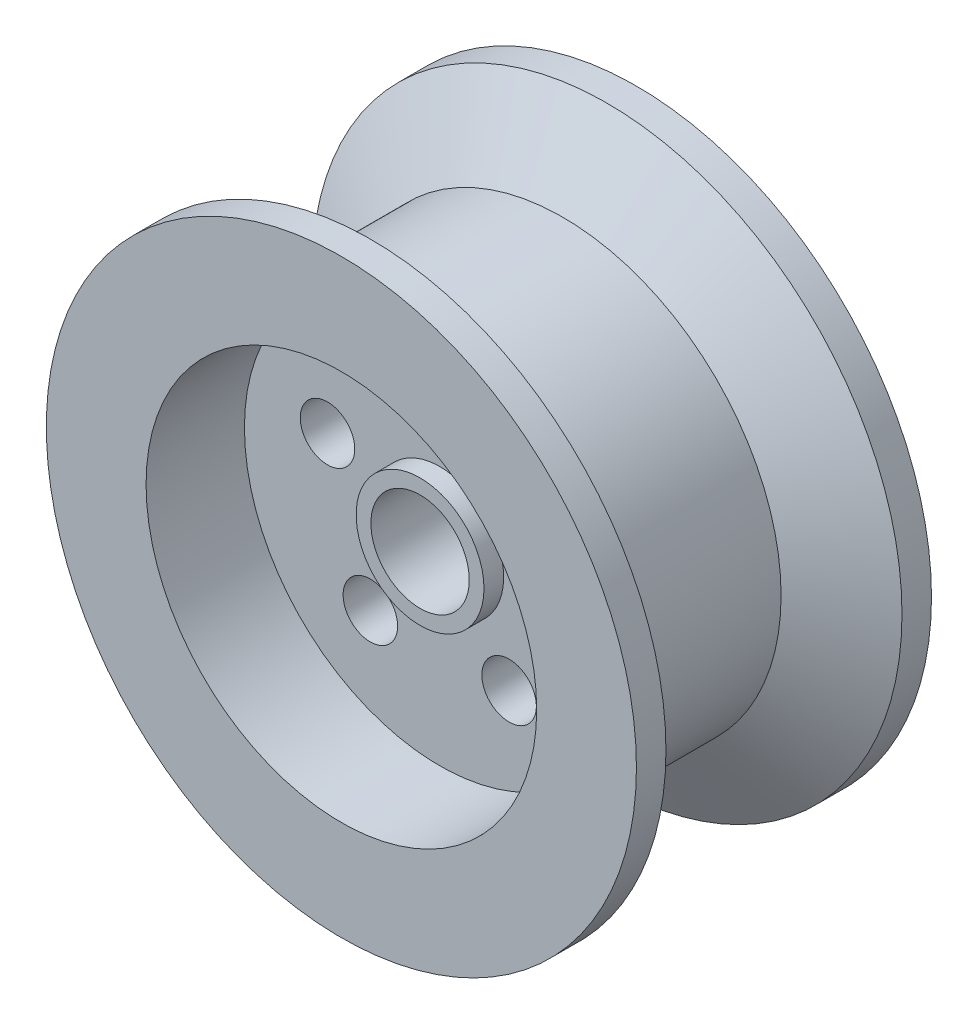
from build123d import *

# Parameters (mm, degrees)
SKETCH1_R                = 30
SKETCH1_R_2              = 5
BOSS_EXTRUDE3_DEPTH      = 30
SKETCH2_R                = 19.858143103
CUT_EXTRUDE1_DEPTH       = 10
SKETCH3_R                = 2.771368275
CUT_EXTRUDE2_DEPTH       = 21
SKETCH4_R                = 6.5
SKETCH4_R_2              = 5
BOSS_EXTRUDE4_DEPTH      = 2
BOSS_EXTRUDE4_DEPTH_BACK = 7


with BuildPart() as part:
    # Sketch1 → Boss-Extrude3 (new body)
    with BuildSketch(Plane.XY):
        Circle(SKETCH1_R)
        Circle(SKETCH1_R_2, mode=Mode.SUBTRACT)
    extrude(amount=BOSS_EXTRUDE3_DEPTH)

    # Sketch2 → Cut-Extrude1 (cut)
    with BuildSketch(Plane.XY.offset(30)):
        Circle(SKETCH2_R)
    cut_extrude1 = extrude(amount=-CUT_EXTRUDE1_DEPTH, mode=Mode.SUBTRACT)

    # Mirror1: Cut-Extrude1 across plane
    add(cut_extrude1.mirror(Plane.XY), mode=Mode.SUBTRACT)

    # Sketch3 → Cut-Extrude2 (cut, through all)
    with BuildSketch(Plane.XY.offset(20)):
        with Locations((0, 12)):
            Circle(SKETCH3_R)
        with Locations((11.412678196, 3.708203932)):
            Circle(SKETCH3_R)
        with Locations((7.053423028, -9.708203932)):
            Circle(SKETCH3_R)
        with Locations((-7.053423028, -9.708203932)):
            Circle(SKETCH3_R)
        with Locations((-11.412678196, 3.708203932)):
            Circle(SKETCH3_R)
    extrude(amount=-CUT_EXTRUDE2_DEPTH, mode=Mode.SUBTRACT)

    # Sketch4 → Boss-Extrude4 (add, two sides)
    with BuildSketch(Plane.XY.offset(20)) as boss_extrude4_sk:
        Circle(SKETCH4_R)
        Circle(SKETCH4_R_2, mode=Mode.SUBTRACT)
    extrude(amount=BOSS_EXTRUDE4_DEPTH)
    extrude(boss_extrude4_sk.sketch, amount=-BOSS_EXTRUDE4_DEPTH_BACK)

    # Sketch5 → Cut-Revolve1 (revolve, cut)
    with BuildSketch(Plane(origin=(0, 0, 0), x_dir=(1, 0, 0), z_dir=(0, 1, 0))):
        Polygon((30, -3), (22.205771366, -7.5), (22.205771366, -22.5), (30, -27), align=None)
    revolve(axis=Axis((0, 0, 0), (0, 0, -1)), mode=Mode.SUBTRACT)


solid = part.part
